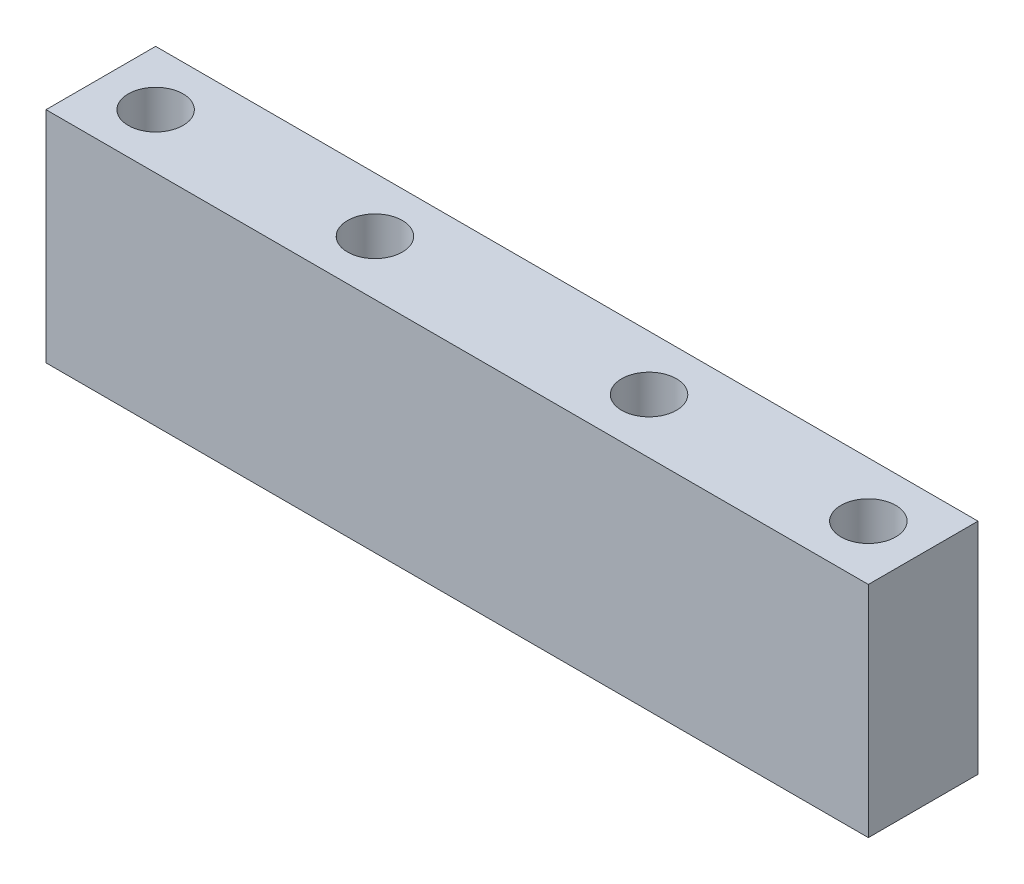
from build123d import *

# Parameters (mm, degrees)
SKETCH1_W           = 95.25
SKETCH1_H           = 12.7
SKETCH1_R           = 3.175
BOSS_EXTRUDE1_DEPTH = 25.4


with BuildPart() as part:
    # Sketch1 → Boss-Extrude1 (new body)
    with BuildSketch(Plane(origin=(0, 0, 0), x_dir=(1, 0, 0), z_dir=(0, 1, 0))):
        Rectangle(SKETCH1_W, SKETCH1_H)
        with Locations((-41.275, 0)):
            Circle(SKETCH1_R, mode=Mode.SUBTRACT)
        with Locations((41.275, 0)):
            Circle(SKETCH1_R, mode=Mode.SUBTRACT)
        with Locations((-15.875, 0)):
            Circle(SKETCH1_R, mode=Mode.SUBTRACT)
        with Locations((15.875, 0)):
            Circle(SKETCH1_R, mode=Mode.SUBTRACT)
    extrude(amount=BOSS_EXTRUDE1_DEPTH)


solid = part.part
